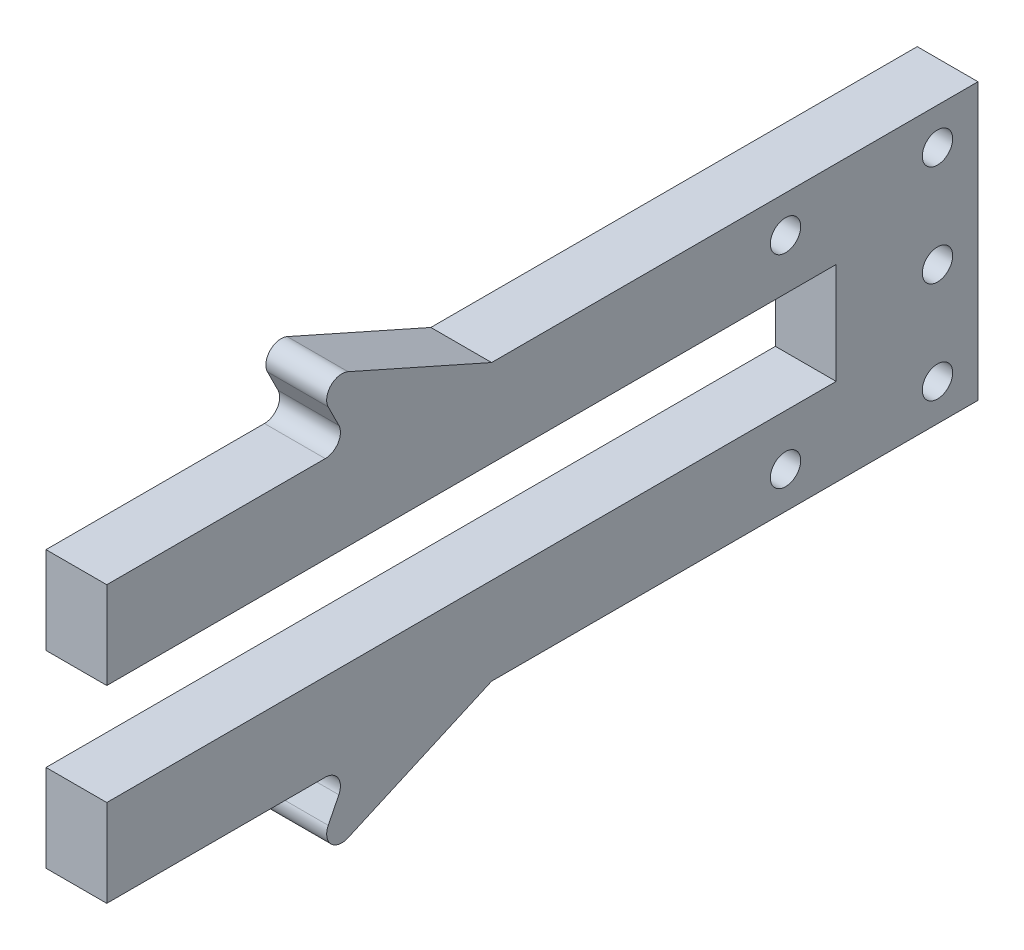
from build123d import *

# Parameters (mm, degrees)
BOSS_EXTRUDE1_DEPTH = 3
FILLET1_R           = 0.75
SKETCH3_R           = 0.75
CUT_EXTRUDE1_DEPTH  = 4


with BuildPart() as part:
    # Sketch2 → Boss-Extrude1 (new body)
    with BuildSketch(Plane(origin=(0, 0, 0), x_dir=(0, 0, -1), z_dir=(1, 0, 0))):
        Polygon((-20.913575794, -4.388518255), (-8.919601915, -4.388518255), (-10.913575794, -0.388518255), (-1.919601915, -4.388518255), (22.086424206, -4.388518255), (22.086424206, -18.00920791), (-1.919601915, -18.00920791), (-10.913575794, -22.00920791), (-8.919601915, -18.00920791), (-20.913575794, -18.00920791), (-20.913575794, -13.698863083), (15.086424206, -13.698863083), (15.086424206, -8.698863083), (-20.913575794, -8.698863083), align=None)
    extrude(amount=BOSS_EXTRUDE1_DEPTH)

    # Fillet1
    fillet1_edges = [part.edges().sort_by_distance(p)[0] for p in [
        (1.5, -4.388518255, 8.919601915),
        (1.5, -0.388518255, 10.913575794),
        (1.5, -22.00920791, 10.913575794),
        (1.5, -18.00920791, 8.919601915),
    ]]
    fillet(fillet1_edges, radius=FILLET1_R)

    # Sketch3 → Cut-Extrude1 (cut, through all)
    with BuildSketch(Plane(origin=(3, 0, 0), x_dir=(0, 0, -1), z_dir=(1, 0, 0))):
        with Locations((20.086424206, -6.198863083)):
            Circle(SKETCH3_R)
        with Locations((20.086424206, -16.198863083)):
            Circle(SKETCH3_R)
        with Locations((20.086424206, -11.198863083)):
            Circle(SKETCH3_R)
        with Locations((12.586424206, -6.198863083)):
            Circle(SKETCH3_R)
        with Locations((12.586424206, -16.198863083)):
            Circle(SKETCH3_R)
    extrude(amount=-CUT_EXTRUDE1_DEPTH, mode=Mode.SUBTRACT)


solid = part.part
